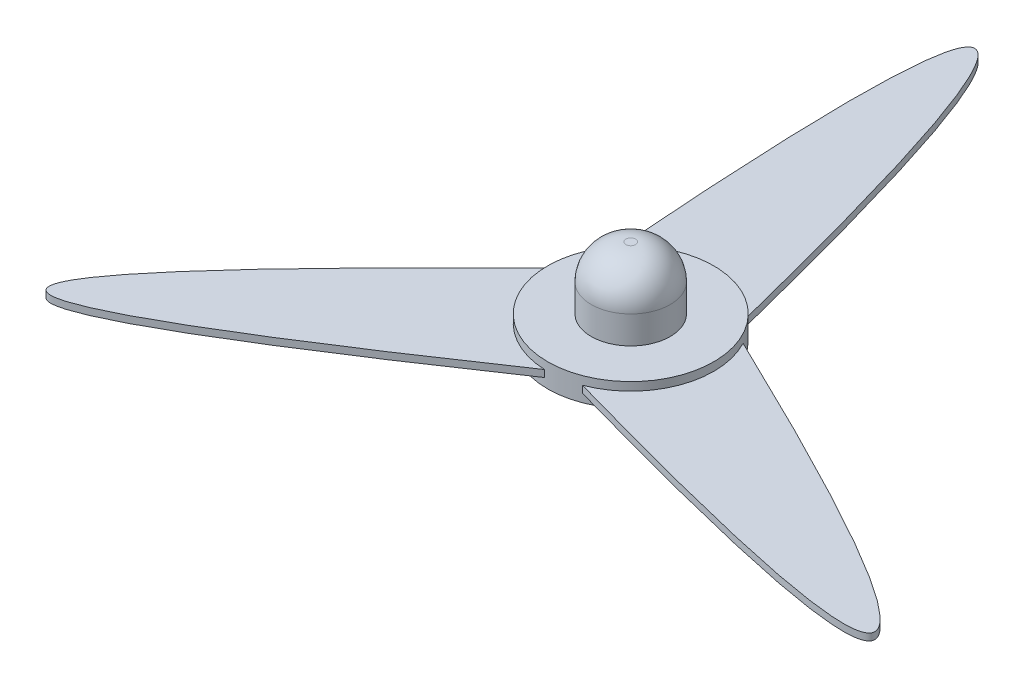
from build123d import *
from build123d.topology import SkipClean

# Parameters (mm, degrees)
BOSS_EXTRUDE1_DEPTH      = 2.5
BOSS_EXTRUDE1_DEPTH_BACK = 2.5
BOSS_EXTRUDE2_DEPTH      = 6
BOSS_EXTRUDE2_DEPTH_BACK = 11
SKETCH3_R                = 60
SKETCH4_R                = 28.5
BOSS_EXTRUDE5_DEPTH      = 45
FILLET4_R                = 25
SKETCH5_R                = 24
CUT_EXTRUDE2_DEPTH       = 37


with BuildPart() as part:
    # Sketch1 → Boss-Extrude1 (new, two sides: drawn at the far end of the back side and taken through both)
    with BuildSketch(Plane(origin=(0, 0, 0), x_dir=(1, 0, 0), z_dir=(0, 1, 0)).offset(-BOSS_EXTRUDE1_DEPTH_BACK)):
        with BuildLine():
            ThreePointArc((-50.816530808, 31.901100241), (-56.123031071, 21.218043817), (-59.211320918, 9.696364016))
            add(Edge.make_bspline(
                [(-2.218897813, -59.958956733), (-433.653695627, -354.818191007), (-59.211320918, 9.696364016)],
                knots=[0, 0, 0, 1, 1, 1], degree=2))
            ThreePointArc((-2.218897813, -59.958956733), (9.686150572, -59.212992553), (21.208362897, -56.126690115))
            add(Edge.make_bspline(
                [(53.035428622, 28.057856492), (524.108414951, -198.146021355), (21.208362897, -56.126690115)],
                knots=[0, 0, 0, 1, 1, 1], degree=2))
            ThreePointArc((53.035428622, 28.057856492), (46.436880499, 37.994948737), (38.002958021, 46.430326099))
            add(Edge.make_bspline(
                [(-50.816530808, 31.901100241), (-90.454719323, 552.964212362), (38.002958021, 46.430326099)],
                knots=[0, 0, 0, 1, 1, 1], degree=2))
        make_face()
    extrude(amount=BOSS_EXTRUDE1_DEPTH + BOSS_EXTRUDE1_DEPTH_BACK)

    # Sketch3 → Boss-Extrude2 (add, two sides: drawn at the far end of the back side and taken through both)
    with SkipClean():  # the faces are left unmerged after this step: merging them gives an invalid solid
        with BuildSketch(Plane(origin=(0, 2.5, 0), x_dir=(1, 0, 0), z_dir=(0, 1, 0)).offset(-BOSS_EXTRUDE2_DEPTH_BACK)):
            Circle(SKETCH3_R)
        extrude(amount=BOSS_EXTRUDE2_DEPTH + BOSS_EXTRUDE2_DEPTH_BACK)

    # Sketch4 → Boss-Extrude5 (add)
    with SkipClean():  # the faces are left unmerged after this step: merging them gives an invalid solid
        with BuildSketch(Plane(origin=(0, 8.5, 0), x_dir=(1, 0, 0), z_dir=(0, 1, 0))):
            Circle(SKETCH4_R)
        extrude(amount=BOSS_EXTRUDE5_DEPTH)

    # Fillet4
    fillet4_edges = [part.edges().sort_by_distance(p)[0] for p in [
        (-28.5, 53.5, 0),
    ]]
    fillet(fillet4_edges, radius=FILLET4_R)

    # Sketch5 → Cut-Extrude2 (cut)
    with BuildSketch(Plane.XZ.offset(8.5)):
        Circle(SKETCH5_R)
    extrude(amount=-CUT_EXTRUDE2_DEPTH, mode=Mode.SUBTRACT)


solid = part.part
